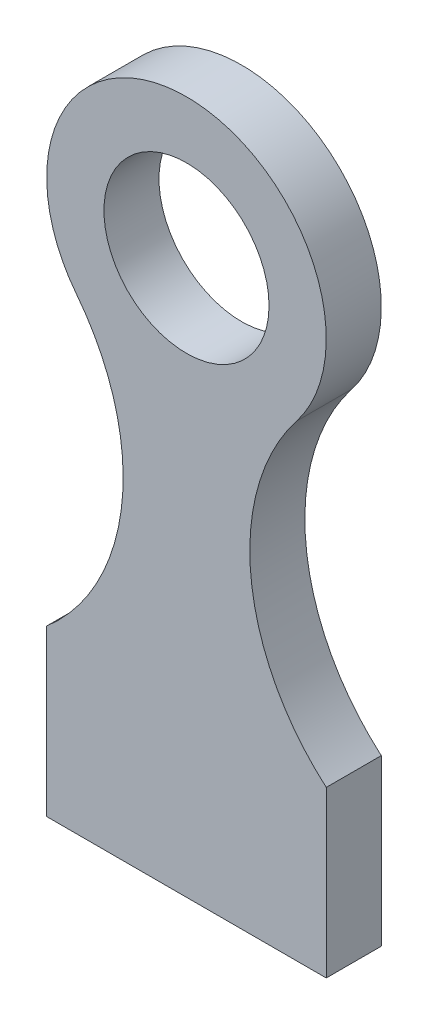
from build123d import *

# Parameters (mm, degrees)
SKETCH1_R           = 0.75
BOSS_EXTRUDE1_DEPTH = 0.5


with BuildPart() as part:
    # Sketch1 → Boss-Extrude1 (new body)
    with BuildSketch(Plane.XY):
        with BuildLine():
            Line((-0.393333333, -3.017777778), (2.146666667, -3.017777778))
            Line((2.146666667, -3.017777778), (2.146666667, -1.517777778))
            ThreePointArc((2.146666667, -1.517777778), (1.4617431, -0.198043481), (1.876940292, 1.229692558))
            ThreePointArc((1.876940292, 1.229692558), (0.876666667, 3.282222222), (-0.123606959, 1.229692558))
            ThreePointArc((-0.123606959, 1.229692558), (0.291590233, -0.198043481), (-0.393333333, -1.517777778))
            Line((-0.393333333, -1.517777778), (-0.393333333, -3.017777778))
        make_face()
        with Locations((0.876666667, 2.012222222)):
            Circle(SKETCH1_R, mode=Mode.SUBTRACT)
    extrude(amount=BOSS_EXTRUDE1_DEPTH)


solid = part.part
